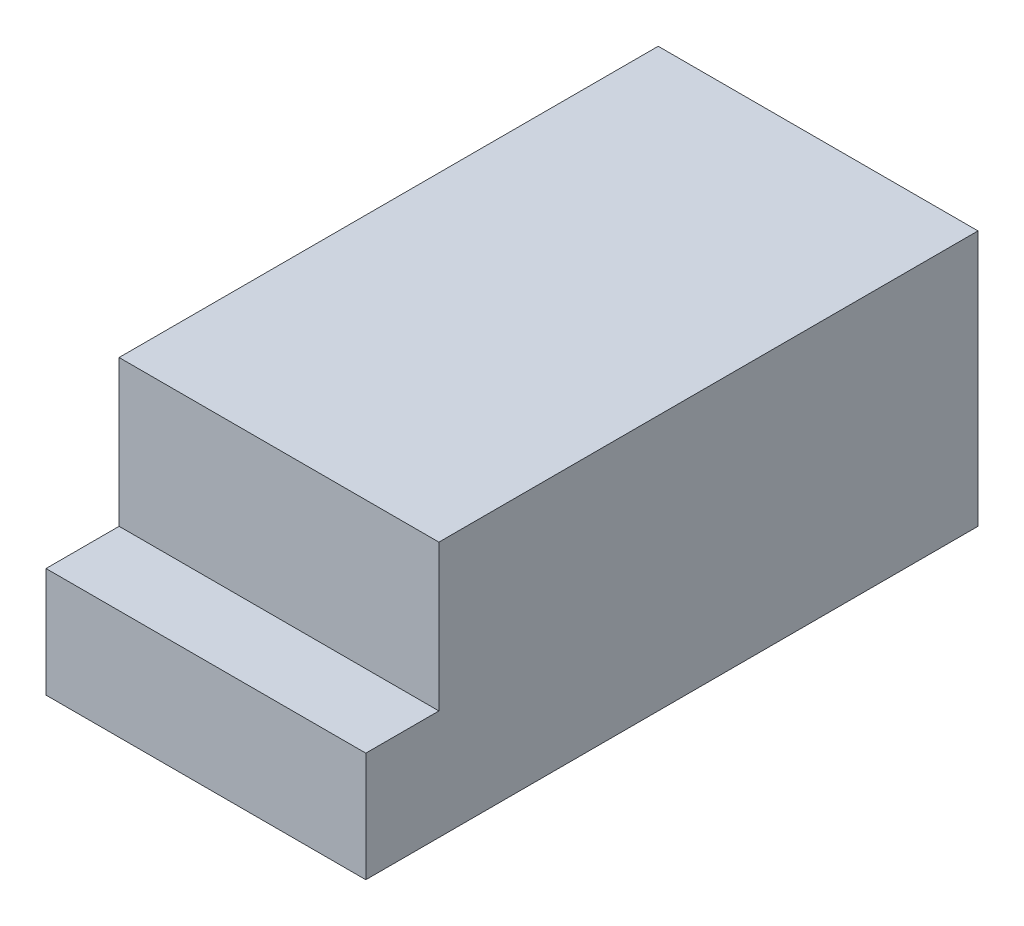
from build123d import *

# Parameters (mm, degrees)
SKETCH2_W           = 111.125
SKETCH2_H           = 88.9
BOSS_EXTRUDE1_DEPTH = 212.725
SKETCH4_W           = 111.125
SKETCH4_H           = 50.8
CUT_EXTRUDE1_DEPTH  = 25.4


with BuildPart() as part:
    # Sketch2 → Boss-Extrude1 (new body)
    with BuildSketch(Plane.XY):
        Rectangle(SKETCH2_W, SKETCH2_H)
    extrude(amount=BOSS_EXTRUDE1_DEPTH)

    # Sketch4 → Cut-Extrude1 (cut)
    with BuildSketch(Plane.XY.offset(212.725)):
        with Locations((0, 19.05)):
            Rectangle(SKETCH4_W, SKETCH4_H)
    extrude(amount=-CUT_EXTRUDE1_DEPTH, mode=Mode.SUBTRACT)


solid = part.part
